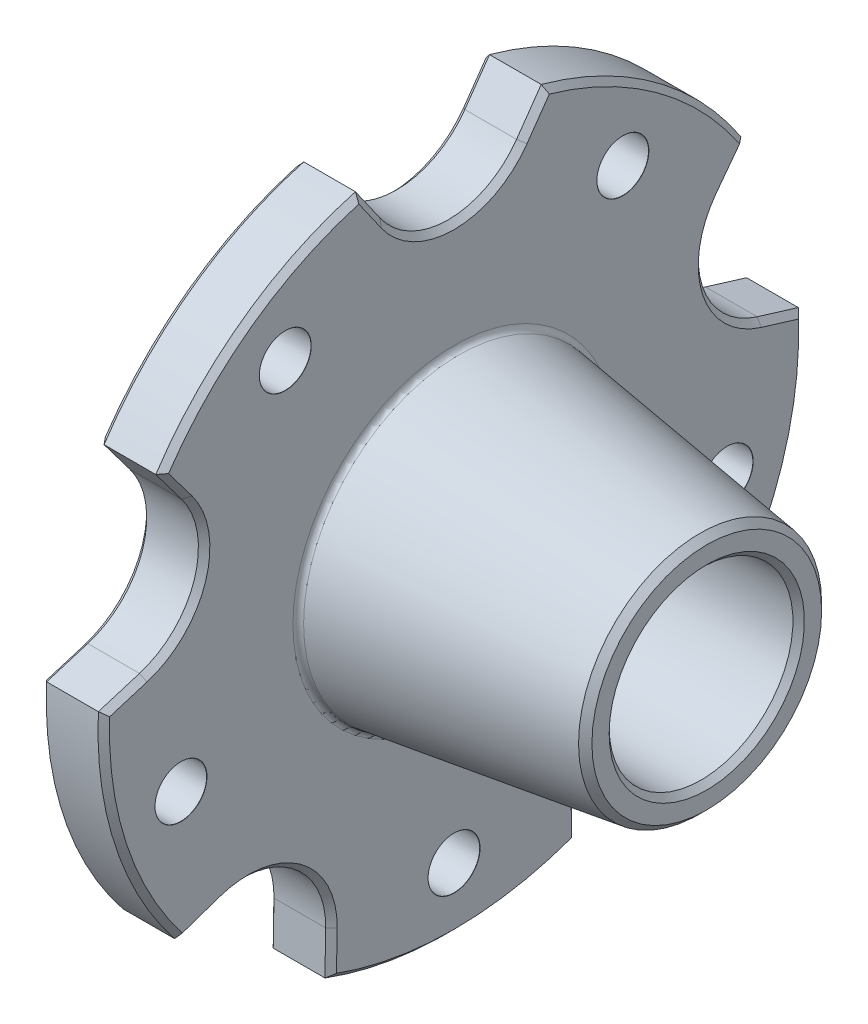
from build123d import *
from OCP.BRepFilletAPI import BRepFilletAPI_MakeChamfer

# Parameters (mm, degrees)
CUT_EXTRUDE2_REACH = 104.308
FILLET1_R          = 1
CIRPATTERN6_COUNT  = 5
CHAMFER2_SIZE      = 1
CHAMFER2_SIZE2     = 1.174957012


with BuildPart() as part:
    # Sketch1 → Revolve1 (revolve)
    with BuildSketch(Plane.XY, mode=Mode.PRIVATE) as revolve1_sk:
        Polygon((0, 12), (0, 25), (15, 25), (15, 61), (26, 61), (26, 27.183796727), (70, 21), (70, 16), (38, 16), (38, 8), (12, 8), (12, 12), align=None)
    revolve(revolve1_sk.sketch.rotate(Axis((0, 0, 0), (1, 0, 0)), 90), axis=Axis((0, 0, 0), (1, 0, 0)))

    # Sketch3 → Cut-Extrude2 (cut, up to next)
    with BuildSketch(Plane.ZY.offset(-15), mode=Mode.PRIVATE) as cut_extrude2_sk1:
        with BuildLine():
            Line((-11.877704642, 52.683141673), (-16.172703347, 58.817035512))
            ThreePointArc((-16.172703347, 58.817035512), (0, 61), (16.172703347, 58.817035512))
            Line((16.172703347, 58.817035512), (11.877704642, 52.683141673))
            ThreePointArc((11.877704642, 52.683141673), (0, 46.5), (-11.877704642, 52.683141673))
        make_face()
    cut_extrude2_tool1 = extrude(cut_extrude2_sk1.sketch, amount=-CUT_EXTRUDE2_REACH, mode=Mode.PRIVATE) & part.part
    cut_extrude2 = cut_extrude2_tool1.solids().sort_by_distance((15, 54.623829, 0))[0]
    add(cut_extrude2, mode=Mode.SUBTRACT)

    # Fillet1
    fillet1_edges = [part.edges().sort_by_distance(p)[0] for p in [
        (38, 0, -16),
        (26, 0, -27.183796727),
        (15, 0, -25),
        (12, 0, -12),
    ]]
    fillet(fillet1_edges, radius=FILLET1_R)

    # Sketch6 → M3 Clearance Hole2 (revolve, cut)
    with BuildSketch(Plane(origin=(15, 40.450849719, -29.389262615), x_dir=(0, 0, 1), z_dir=(0, 1, 0))):
        Polygon((0, 0), (0, 11), (4.525, 11), (4.5, 10.975), (4.5, 0.025), (4.525, 0), align=None)
    m3_clearance_hole2 = revolve(axis=Axis((8.65, 40.450849719, -29.389262615), (1, 0, 0)), mode=Mode.SUBTRACT)

    # CirPattern6: Cut-Extrude2, M3 Clearance Hole2 ×5 about axis
    cirpattern6_axis = Axis((0, 0, 0), (1, 0, 0))
    add([cut_extrude2.rotate(cirpattern6_axis, i * 360 / CIRPATTERN6_COUNT) for i in range(1, CIRPATTERN6_COUNT)], mode=Mode.SUBTRACT)
    add([m3_clearance_hole2.rotate(cirpattern6_axis, i * 360 / CIRPATTERN6_COUNT) for i in range(1, CIRPATTERN6_COUNT)], mode=Mode.SUBTRACT)

    # Chamfer2: one chamfer whose edges measure the first distance from different faces: ONE call of the kernel's chamfer builder (chamfer() names one face for all edges)
    chamfer2_edges_1 = [part.edges().sort_by_distance(p)[0] for p in [
        (26, 3.888963162, 57.355511424),
        (38, 0, -8),
        (26, 14.369290238, 44.224128008),
        (26, 30.566486464, 48.687458656),
        (15, 30.566486464, 48.687458656),
        (15, 14.369290238, 44.224128008),
        (15, 3.888963162, 57.355511424),
        (70, 0, -16),
        (0, 0, -25),
        (0, 0, -12),
        (26, 49.350036657, -35.85490039),
        (15, 49.350036657, -35.85490039),
        (15, 46.5, 0),
        (15, 55.750088593, 14.025203995),
        (15, 55.750088593, -14.025203995),
        (26, 46.5, 0),
        (26, 55.750088593, -14.025203995),
        (26, 55.750088593, 14.025203995),
        (26, -18.850036657, -58.014447494),
        (26, -61, 0),
        (26, -18.850036657, 58.014447494),
        (26, 49.350036657, 35.85490039),
        (15, -18.850036657, -58.014447494),
        (15, -61, 0),
        (15, -18.850036657, 58.014447494),
        (15, 49.350036657, 35.85490039),
        (26, 30.566486464, -48.687458656),
        (26, 14.369290238, -44.224128008),
        (26, 3.888963162, -57.355511424),
        (15, 3.888963162, -57.355511424),
        (15, 14.369290238, -44.224128008),
        (15, 30.566486464, -48.687458656),
        (26, -36.858961041, -44.11570827),
        (26, -37.619290238, -27.332014232),
        (26, -53.346577178, -21.422451507),
        (15, -53.346577178, -21.422451507),
        (15, -37.619290238, -27.332014232),
        (15, -36.858961041, -44.11570827),
        (12, 0, -8),
        (26, -53.346577178, 21.422451507),
        (26, -37.619290238, 27.332014232),
        (26, -36.858961041, 44.11570827),
        (15, -36.858961041, 44.11570827),
        (15, -37.619290238, 27.332014232),
        (15, -53.346577178, 21.422451507),
    ]]
    chamfer2_edges_2 = [part.edges().sort_by_distance(p)[0] for p in [
        (70, 0, -21),
    ]]
    chamfer2_side_2 = [part.faces().sort_by_distance(p)[0] for p in [
        (70, 0, -20.406030304),
    ]]
    chamfer2 = BRepFilletAPI_MakeChamfer(part.part.solid().wrapped)
    for e in chamfer2_edges_1:
        chamfer2.Add(CHAMFER2_SIZE, e.wrapped)
    for e in chamfer2_edges_2:
        chamfer2.Add(CHAMFER2_SIZE, CHAMFER2_SIZE2, e.wrapped, chamfer2_side_2[0].wrapped)  # the first distance lies on this face
    add(Compound.cast(chamfer2.Shape()), mode=Mode.REPLACE)


solid = part.part
